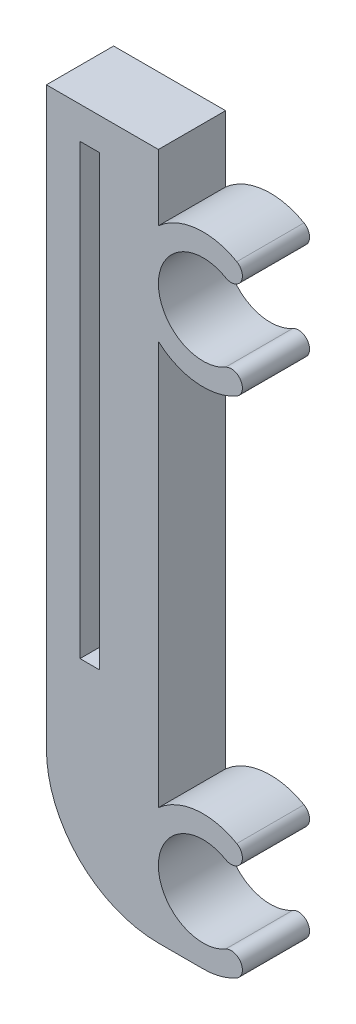
from build123d import *

# Parameters (mm, degrees)
BOSS_EXTRUDE_BASE_DEPTH = 6
SKETCH4_W               = 1.75
SKETCH4_H               = 40
CUT_EXTRUDE_SLOT_DEPTH  = 4.5


with BuildPart() as part:
    # Sketch1 → Boss-Extrude-Base (new body)
    with BuildSketch(Plane.XY):
        with BuildLine():
            Line((10.072988134, 10.472135955), (10.072988134, 46.527864045))
            ThreePointArc((10.072988134, 46.527864045), (13.45569569, 45.031838638), (17.072988134, 45.803847577))
            ThreePointArc((17.072988134, 45.803847577), (17.439013538, 47.169872981), (16.072988134, 47.535898385))
            ThreePointArc((16.072988134, 47.535898385), (10.072988134, 51), (16.072988134, 54.464101615))
            ThreePointArc((16.072988134, 54.464101615), (17.439013538, 54.830127019), (17.072988134, 56.196152423))
            ThreePointArc((17.072988134, 56.196152423), (13.45569569, 56.968161362), (10.072988134, 55.472135955))
            Line((10.072988134, 55.472135955), (10.072988134, 61.375))
            Line((10.072988134, 61.375), (0.072988134, 61.375))
            Line((0.072988134, 61.375), (0.072988134, 10))
            ThreePointArc((0.072988134, 10), (3.001920322, 2.928932188), (10.072988134, 0))
            Line((10.072988134, 0), (14.072988134, 0))
            ThreePointArc((14.072988134, 0), (15.625902405, 0.204445042), (17.072988134, 0.803847577))
            ThreePointArc((17.072988134, 0.803847577), (17.439013538, 2.169872981), (16.072988134, 2.535898385))
            ThreePointArc((16.072988134, 2.535898385), (10.072988134, 6), (16.072988134, 9.464101615))
            ThreePointArc((16.072988134, 9.464101615), (17.439013538, 9.830127019), (17.072988134, 11.196152423))
            ThreePointArc((17.072988134, 11.196152423), (13.45569569, 11.968161362), (10.072988134, 10.472135955))
        make_face()
    extrude(amount=BOSS_EXTRUDE_BASE_DEPTH)

    # Sketch4 → Cut-Extrude-Slot (cut)
    with BuildSketch(Plane.XY.offset(6)):
        with Locations((3.947988134, 38.5)):
            Rectangle(SKETCH4_W, SKETCH4_H)
    extrude(amount=-CUT_EXTRUDE_SLOT_DEPTH, mode=Mode.SUBTRACT)


solid = part.part
